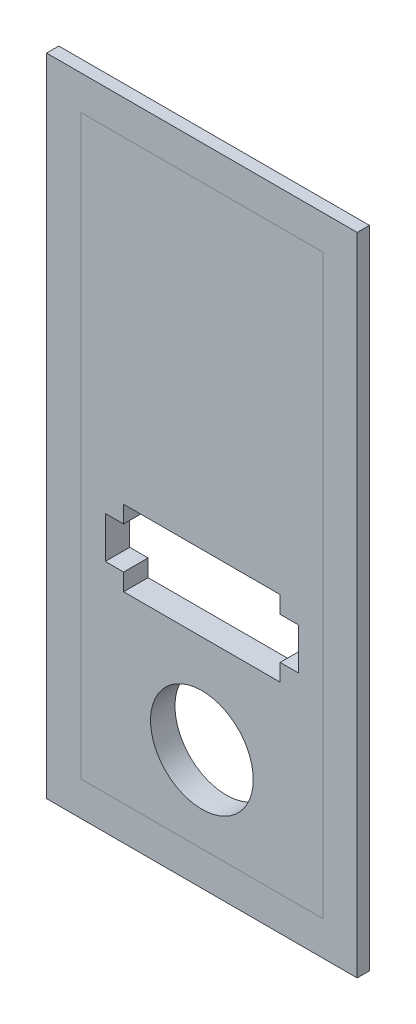
from build123d import *

# Parameters (mm, degrees)
ESQUISSE2_W        = 19.8
ESQUISSE2_H        = 47.2
ESQUISSE2_R        = 4.2
BOSS_EXTRU_1_DEPTH = 2
ESQUISSE3_W        = 25.4
ESQUISSE3_H        = 52.8
ESQUISSE3_W_2      = 19.8
ESQUISSE3_H_2      = 47.2
BOSS_EXTRU_2_DEPTH = 1


with BuildPart() as part:
    # Esquisse2 → Boss.-Extru.1 (new body)
    with BuildSketch(Plane.XY):
        with Locations((0, 16.6)):
            Rectangle(ESQUISSE2_W, ESQUISSE2_H)
        Circle(ESQUISSE2_R, mode=Mode.SUBTRACT)
        Polygon((-6.4, 12.8), (-6.4, 14.2), (6.4, 14.2), (6.4, 12.8), (7.9, 12.8), (7.9, 9.4), (6.4, 9.4), (6.4, 8), (-6.4, 8), (-6.4, 9.4), (-7.9, 9.4), (-7.9, 12.8), align=None, mode=Mode.SUBTRACT)
    extrude(amount=BOSS_EXTRU_1_DEPTH)


with BuildPart() as body_2:
    # Esquisse3 → Boss.-Extru.2 (new body)
    with BuildSketch(Plane.XY.offset(2)):
        with Locations((0, 16.6)):
            Rectangle(ESQUISSE3_W, ESQUISSE3_H)
        with Locations((0, 16.6)):
            Rectangle(ESQUISSE3_W_2, ESQUISSE3_H_2, mode=Mode.SUBTRACT)
    extrude(amount=-BOSS_EXTRU_2_DEPTH)


solid = Compound([part.part, body_2.part])
